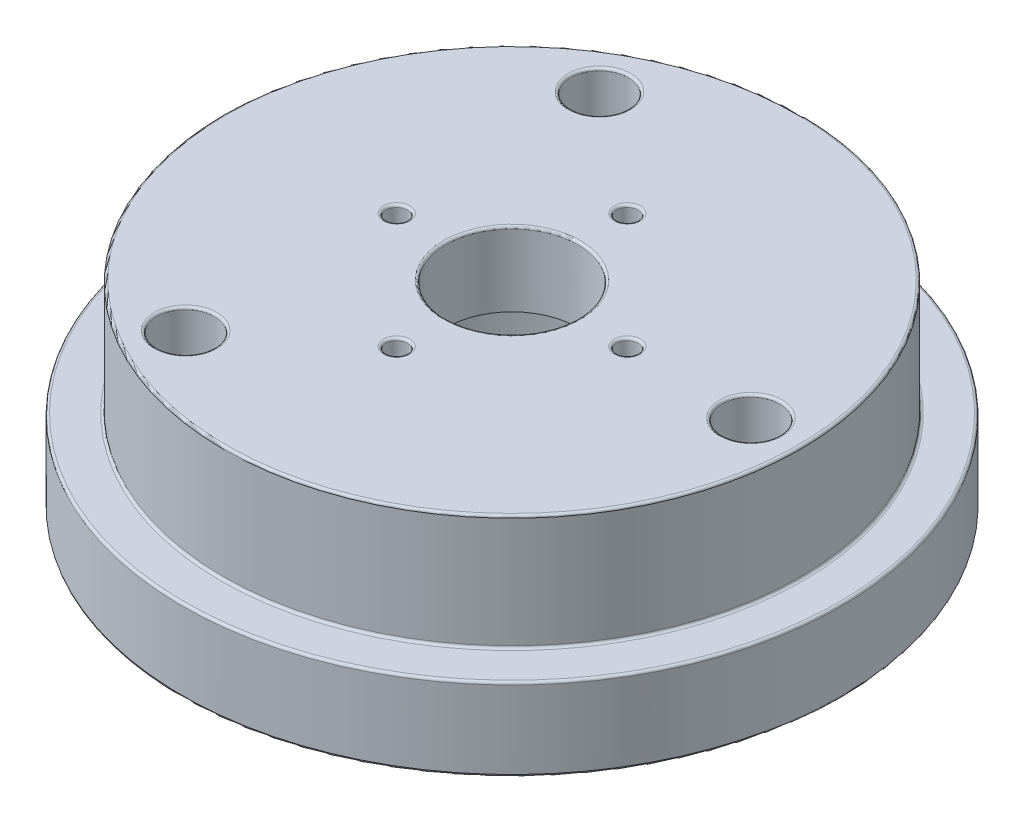
from build123d import *

# Parameters (mm, degrees)
SKETCH3_R          = 1.75
SKETCH3_R_2        = 4
SKETCH3_R_3        = 0.65
CUT_EXTRUDE1_DEPTH = 31.724582991
SKETCH3_3_R        = 10
SKETCH3_3_R_2      = 4
SKETCH3_3_R_3      = 0.65
SKETCH3_3_R_4      = 1.75
CUT_EXTRUDE2_DEPTH = 7.5
FILLET1_R          = 0.15


with BuildPart() as part:
    # Sketch2 → Revolve1 (revolve)
    with BuildSketch(Plane.XY):
        Polygon((0, 0), (-20, 0), (-20, 5), (-17.5, 5), (-17.5, 12), (0, 12), align=None)
    revolve(axis=Axis((0, 12, 0), (0, -1, 0)))

    # Sketch3 → Cut-Extrude1 (cut, through all)
    with BuildSketch(Plane.XZ):
        with Locations((14.5, 0)):
            Circle(SKETCH3_R)
        with Locations((-7.25, -12.557368355)):
            Circle(SKETCH3_R)
        with Locations((-7.25, 12.557368355)):
            Circle(SKETCH3_R)
        Circle(SKETCH3_R_2)
        with Locations((7, 0)):
            Circle(SKETCH3_R_3)
        with Locations((0, -7)):
            Circle(SKETCH3_R_3)
        with Locations((-7, 0)):
            Circle(SKETCH3_R_3)
        with Locations((0, 7)):
            Circle(SKETCH3_R_3)
    extrude(amount=-CUT_EXTRUDE1_DEPTH, mode=Mode.SUBTRACT)

    # Sketch3_3 → Cut-Extrude2 (cut)
    # profile 1 of 4: a face of its own
    with BuildSketch(Plane.XZ):
        Circle(SKETCH3_3_R)
        Circle(SKETCH3_3_R_2, mode=Mode.SUBTRACT)
        with Locations((7, 0)):
            Circle(SKETCH3_3_R_3, mode=Mode.SUBTRACT)
        with Locations((0, -7)):
            Circle(SKETCH3_3_R_3, mode=Mode.SUBTRACT)
        with Locations((-7, 0)):
            Circle(SKETCH3_3_R_3, mode=Mode.SUBTRACT)
        with Locations((0, 7)):
            Circle(SKETCH3_3_R_3, mode=Mode.SUBTRACT)
    # profile 2 of 4: a face of its own
    with BuildSketch(Plane.XZ):
        with Locations((14.5, 0)):
            Circle(SKETCH3_3_R_4)
    # profile 3 of 4: a face of its own
    with BuildSketch(Plane.XZ):
        with Locations((-7.25, -12.557368355)):
            Circle(SKETCH3_3_R_4)
    # profile 4 of 4: a face of its own
    with BuildSketch(Plane.XZ):
        with Locations((-7.25, 12.557368355)):
            Circle(SKETCH3_3_R_4)
    extrude(amount=-CUT_EXTRUDE2_DEPTH, mode=Mode.SUBTRACT)

    # Fillet1
    fillet1_edges = [part.edges().sort_by_distance(p)[0] for p in [
        (20, 0, 0),
        (-9, 0, -12.557368355),
        (12.75, 0, 0),
        (-9, 0, 12.557368355),
        (-10, 0, 0),
        (17.5, 5, 0),
        (20, 5, 0),
        (17.5, 12, 0),
        (-7.65, 12, 0),
        (6.35, 12, 0),
        (-0.65, 12, 7),
        (-0.65, 12, -7),
        (-4, 12, 0),
        (-9, 12, -12.557368355),
        (12.75, 12, 0),
        (-9, 12, 12.557368355),
    ]]
    fillet(fillet1_edges, radius=FILLET1_R)


solid = part.part
